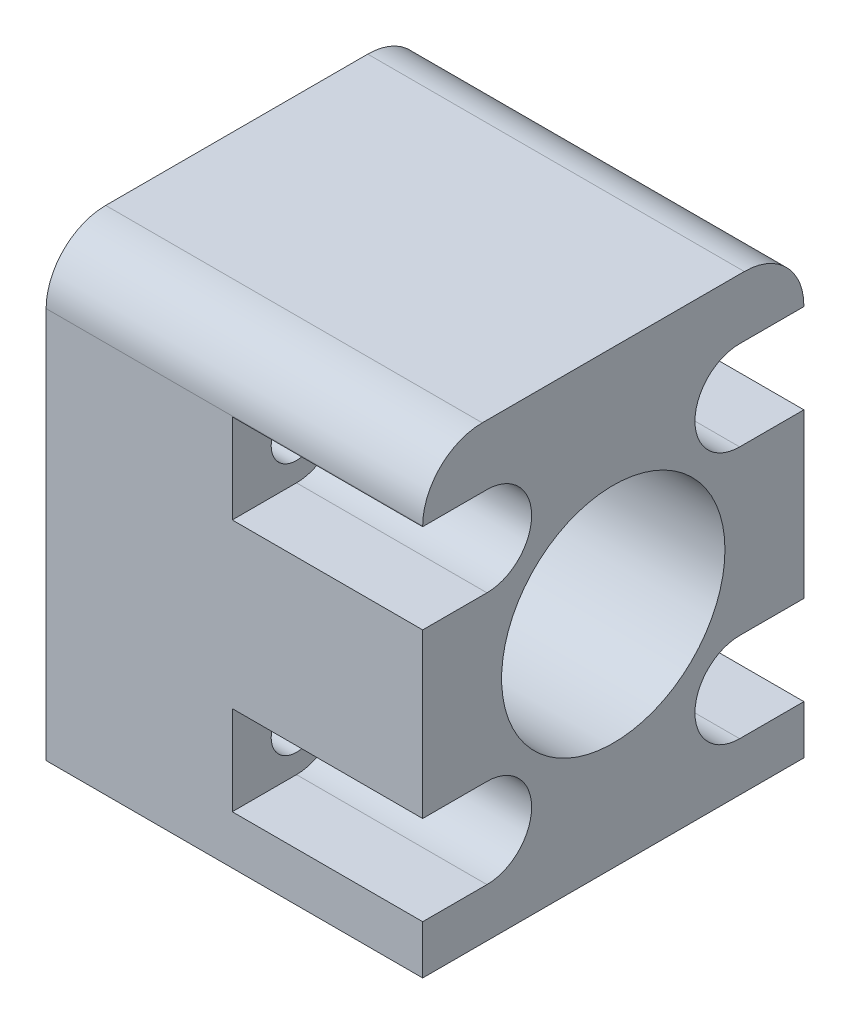
from build123d import *

# Parameters (mm, degrees)
ESQUISSE1_W                  = 59
ESQUISSE1_H                  = 140
ESQUISSE1_R                  = 4
BOSS_EXTRU_1_DEPTH           = 25.6
ESQUISSE2_R                  = 7.5
ESQUISSE2_R_2                = 2.6
ENL_V_MAT_EXTRU_1_DEPTH      = 5
ESQUISSE3_R                  = 7.5
ENL_V_MAT_EXTRU_2_DEPTH      = 82
ESQUISSE4_R                  = 2.6
ENL_V_MAT_EXTRU_3_DEPTH      = 5
CONG_1_R                     = 4
ESQUISSE5_R                  = 1.7
ENL_V_MAT_EXTRU_4_DEPTH      = 71
ENL_V_MAT_EXTRU_5_DEPTH      = 17
ENL_V_MAT_EXTRU_5_DEPTH_BACK = 17
ESQUISSE7_W                  = 129.758897747
ESQUISSE7_H                  = 47.788995409
ENL_V_MAT_EXTRU_6_DEPTH      = 109.711687575
ESQUISSE8_W                  = 39.97313833
ESQUISSE8_H                  = 58.643042411
ENL_V_MAT_EXTRU_7_DEPTH      = 33.711687575


with BuildPart() as part:
    # Esquisse1 → Boss.-Extru.1 (new body)
    with BuildSketch(Plane.XY):
        with Locations((91.26696752, -67.893899255)):
            Rectangle(ESQUISSE1_W, ESQUISSE1_H)
        with Locations((115.36696752, -108.722960996)):
            Circle(ESQUISSE1_R, mode=Mode.SUBTRACT)
        with Locations((115.36696752, -26.122960996)):
            Circle(ESQUISSE1_R, mode=Mode.SUBTRACT)
        with Locations((74.86696752, -56.866619083)):
            Circle(ESQUISSE1_R, mode=Mode.SUBTRACT)
        with Locations((67.16696752, -107.582960996)):
            Circle(ESQUISSE1_R, mode=Mode.SUBTRACT)
        with Locations((67.16696752, -32.342960996)):
            Circle(ESQUISSE1_R, mode=Mode.SUBTRACT)
    extrude(amount=BOSS_EXTRU_1_DEPTH)

    # Esquisse2 → Enlèv. mat.-Extru.1 (cut)
    with BuildSketch(Plane(origin=(120.76696752, 0, 0), x_dir=(0, 0, -1), z_dir=(1, 0, 0))):
        with Locations((-12.8, -95.02835166)):
            Circle(ESQUISSE2_R)
        with Locations((-21.285281374, -103.629375049)):
            Circle(ESQUISSE2_R_2)
        with Locations((-4.314718626, -103.629375049)):
            Circle(ESQUISSE2_R_2)
        with Locations((-4.314718626, -86.427328272)):
            Circle(ESQUISSE2_R_2)
        with Locations((-21.285281374, -86.427328272)):
            Circle(ESQUISSE2_R_2)
        with Locations((-21.285281374, -133.513633034)):
            Circle(ESQUISSE2_R_2)
        with Locations((-12.8, -125.02835166)):
            Circle(ESQUISSE2_R)
        with Locations((-4.314718626, -133.513633034)):
            Circle(ESQUISSE2_R_2)
        with Locations((-4.314718626, -69.225281495)):
            Circle(ESQUISSE2_R_2)
        with Locations((-21.285281374, -69.225281495)):
            Circle(ESQUISSE2_R_2)
        with Locations((-12.8, -77.826304883)):
            Circle(ESQUISSE2_R)
        with Locations((-4.314718626, -52.023234718)):
            Circle(ESQUISSE2_R_2)
        with Locations((-21.285281374, -52.023234718)):
            Circle(ESQUISSE2_R_2)
        with Locations((-12.8, -60.624258106)):
            Circle(ESQUISSE2_R)
        with Locations((-4.314718626, -34.821187941)):
            Circle(ESQUISSE2_R_2)
        with Locations((-21.285281374, -34.821187941)):
            Circle(ESQUISSE2_R_2)
        with Locations((-12.8, -43.422211329)):
            Circle(ESQUISSE2_R)
        with Locations((-12.8, -13.422211329)):
            Circle(ESQUISSE2_R)
        with Locations((-21.285281374, -4.936929955)):
            Circle(ESQUISSE2_R_2)
        with Locations((-4.314718626, -4.936929955)):
            Circle(ESQUISSE2_R_2)
        with Locations((-4.314718626, -116.543070286)):
            Circle(ESQUISSE2_R_2)
        with Locations((-21.285281374, -116.543070286)):
            Circle(ESQUISSE2_R_2)
        with Locations((-4.314718626, -21.907492704)):
            Circle(ESQUISSE2_R_2)
        with Locations((-21.285281374, -21.907492704)):
            Circle(ESQUISSE2_R_2)
    extrude(amount=-ENL_V_MAT_EXTRU_1_DEPTH, mode=Mode.SUBTRACT)

    # Esquisse3 → Enlèv. mat.-Extru.2 (cut)
    with BuildSketch(Plane(origin=(120.76696752, 0, 0), x_dir=(0, 0, -1), z_dir=(1, 0, 0))):
        with Locations((-12.8, -125.02835166)):
            Circle(ESQUISSE3_R)
        with Locations((-12.8, -95.02835166)):
            Circle(ESQUISSE3_R)
        with Locations((-12.8, -77.826304883)):
            Circle(ESQUISSE3_R)
        with Locations((-12.8, -60.624258106)):
            Circle(ESQUISSE3_R)
        with Locations((-12.8, -43.422211329)):
            Circle(ESQUISSE3_R)
        with Locations((-12.8, -13.422211329)):
            Circle(ESQUISSE3_R)
    extrude(amount=-ENL_V_MAT_EXTRU_2_DEPTH, mode=Mode.SUBTRACT)

    # Esquisse4 → Enlèv. mat.-Extru.3 (cut)
    with BuildSketch(Plane.ZY.offset(-61.76696752)):
        with Locations((21.285281374, -4.936929955)):
            Circle(ESQUISSE4_R)
        with Locations((4.314718626, -4.936929955)):
            Circle(ESQUISSE4_R)
        with Locations((21.285281374, -34.936929955)):
            Circle(ESQUISSE4_R)
        with Locations((4.314718626, -34.936929955)):
            Circle(ESQUISSE4_R)
        with Locations((4.314718626, -51.907492704)):
            Circle(ESQUISSE4_R)
        with Locations((21.285281374, -51.907492704)):
            Circle(ESQUISSE4_R)
        with Locations((4.314718626, -69.341023509)):
            Circle(ESQUISSE4_R)
        with Locations((21.285281374, -69.341023509)):
            Circle(ESQUISSE4_R)
        with Locations((4.314718626, -86.311586257)):
            Circle(ESQUISSE4_R)
        with Locations((21.285281374, -86.311586257)):
            Circle(ESQUISSE4_R)
        with Locations((4.314718626, -103.745117063)):
            Circle(ESQUISSE4_R)
        with Locations((21.285281374, -103.745117063)):
            Circle(ESQUISSE4_R)
        with Locations((4.314718626, -133.513633034)):
            Circle(ESQUISSE4_R)
        with Locations((21.285281374, -133.513633034)):
            Circle(ESQUISSE4_R)
        with Locations((4.314718626, -21.907492704)):
            Circle(ESQUISSE4_R)
        with Locations((21.285281374, -21.907492704)):
            Circle(ESQUISSE4_R)
        with Locations((4.314718626, -116.543070286)):
            Circle(ESQUISSE4_R)
        with Locations((21.285281374, -116.543070286)):
            Circle(ESQUISSE4_R)
    extrude(amount=-ENL_V_MAT_EXTRU_3_DEPTH, mode=Mode.SUBTRACT)

    # Congé1
    cong_1_edges = [part.edges().sort_by_distance(p)[0] for p in [
        (91.26696752, 2.106100745, 25.6),
        (91.26696752, 2.106100745, 0),
        (91.26696752, -137.893899255, 0),
        (91.26696752, -137.893899255, 25.6),
    ]]
    fillet(cong_1_edges, radius=CONG_1_R)

    # Esquisse5 → Enlèv. mat.-Extru.4 (cut)
    with BuildSketch(Plane.ZY.offset(-61.76696752)):
        with Locations((21.285281374, -4.936929955)):
            Circle(ESQUISSE5_R)
        with Locations((21.285281374, -21.907492704)):
            Circle(ESQUISSE5_R)
        with Locations((21.285281374, -34.936929955)):
            Circle(ESQUISSE5_R)
        with Locations((21.285281374, -51.907492704)):
            Circle(ESQUISSE5_R)
        with Locations((21.285281374, -69.341023509)):
            Circle(ESQUISSE5_R)
        with Locations((21.285281374, -86.311586257)):
            Circle(ESQUISSE5_R)
        with Locations((21.285281374, -103.745117063)):
            Circle(ESQUISSE5_R)
        with Locations((21.285281374, -116.543070286)):
            Circle(ESQUISSE5_R)
        with Locations((21.285281374, -133.513633034)):
            Circle(ESQUISSE5_R)
        with Locations((4.314718626, -4.936929955)):
            Circle(ESQUISSE5_R)
        with Locations((4.314718626, -21.907492704)):
            Circle(ESQUISSE5_R)
        with Locations((4.314718626, -34.936929955)):
            Circle(ESQUISSE5_R)
        with Locations((4.314718626, -51.907492704)):
            Circle(ESQUISSE5_R)
        with Locations((4.314718626, -69.341023509)):
            Circle(ESQUISSE5_R)
        with Locations((4.314718626, -86.311586257)):
            Circle(ESQUISSE5_R)
        with Locations((4.314718626, -103.745117063)):
            Circle(ESQUISSE5_R)
        with Locations((4.314718626, -116.543070286)):
            Circle(ESQUISSE5_R)
        with Locations((4.314718626, -133.513633034)):
            Circle(ESQUISSE5_R)
    extrude(amount=-ENL_V_MAT_EXTRU_4_DEPTH, mode=Mode.SUBTRACT)

    # Esquisse6 → Enlèv. mat.-Extru.5 (cut, two sides)
    with BuildSketch(Plane.ZY.offset(-91.26696752)) as enl_v_mat_extru_5_sk:
        with BuildLine():
            Line((21.285281374, -1.936929955), (29.285281374, -1.936929955))
            ThreePointArc((29.285281374, -1.936929955), (32.285281374, -4.936929955), (29.285281374, -7.936929955))
            Line((29.285281374, -7.936929955), (21.285281374, -7.936929955))
            ThreePointArc((21.285281374, -7.936929955), (18.285281374, -4.936929955), (21.285281374, -1.936929955))
        make_face()
        with BuildLine():
            Line((21.285281374, -18.907492704), (29.285281374, -18.907492704))
            ThreePointArc((29.285281374, -18.907492704), (32.285281374, -21.907492704), (29.285281374, -24.907492704))
            Line((29.285281374, -24.907492704), (21.285281374, -24.907492704))
            ThreePointArc((21.285281374, -24.907492704), (18.285281374, -21.907492704), (21.285281374, -18.907492704))
        make_face()
        with BuildLine():
            Line((21.285281374, -31.936929955), (29.285281374, -31.936929955))
            ThreePointArc((29.285281374, -31.936929955), (32.285281374, -34.936929955), (29.285281374, -37.936929955))
            Line((29.285281374, -37.936929955), (21.285281374, -37.936929955))
            ThreePointArc((21.285281374, -37.936929955), (18.285281374, -34.936929955), (21.285281374, -31.936929955))
        make_face()
        with BuildLine():
            Line((21.285281374, -48.907492704), (29.285281374, -48.907492704))
            ThreePointArc((29.285281374, -48.907492704), (32.285281374, -51.907492704), (29.285281374, -54.907492704))
            Line((29.285281374, -54.907492704), (21.285281374, -54.907492704))
            ThreePointArc((21.285281374, -54.907492704), (18.285281374, -51.907492704), (21.285281374, -48.907492704))
        make_face()
        with BuildLine():
            Line((21.285281374, -66.341023509), (29.285281374, -66.341023509))
            ThreePointArc((29.285281374, -66.341023509), (32.285281374, -69.341023509), (29.285281374, -72.341023509))
            Line((29.285281374, -72.341023509), (21.285281374, -72.341023509))
            ThreePointArc((21.285281374, -72.341023509), (18.285281374, -69.341023509), (21.285281374, -66.341023509))
        make_face()
        with BuildLine():
            Line((21.285281374, -83.311586257), (29.285281374, -83.311586257))
            ThreePointArc((29.285281374, -83.311586257), (32.285281374, -86.311586257), (29.285281374, -89.311586257))
            Line((29.285281374, -89.311586257), (21.285281374, -89.311586257))
            ThreePointArc((21.285281374, -89.311586257), (18.285281374, -86.311586257), (21.285281374, -83.311586257))
        make_face()
        with BuildLine():
            Line((21.285281374, -100.745117063), (29.285281374, -100.745117063))
            ThreePointArc((29.285281374, -100.745117063), (32.285281374, -103.745117063), (29.285281374, -106.745117063))
            Line((29.285281374, -106.745117063), (21.285281374, -106.745117063))
            ThreePointArc((21.285281374, -106.745117063), (18.285281374, -103.745117063), (21.285281374, -100.745117063))
        make_face()
        with BuildLine():
            Line((21.285281374, -113.543070286), (29.285281374, -113.543070286))
            ThreePointArc((29.285281374, -113.543070286), (32.285281374, -116.543070286), (29.285281374, -119.543070286))
            Line((29.285281374, -119.543070286), (21.285281374, -119.543070286))
            ThreePointArc((21.285281374, -119.543070286), (18.285281374, -116.543070286), (21.285281374, -113.543070286))
        make_face()
        with BuildLine():
            Line((21.285281374, -130.513633034), (29.285281374, -130.513633034))
            ThreePointArc((29.285281374, -130.513633034), (32.285281374, -133.513633034), (29.285281374, -136.513633034))
            Line((29.285281374, -136.513633034), (21.285281374, -136.513633034))
            ThreePointArc((21.285281374, -136.513633034), (18.285281374, -133.513633034), (21.285281374, -130.513633034))
        make_face()
        with BuildLine():
            Line((-3.685281374, -1.936929955), (4.314718626, -1.936929955))
            ThreePointArc((4.314718626, -1.936929955), (7.314718626, -4.936929955), (4.314718626, -7.936929955))
            Line((4.314718626, -7.936929955), (-3.685281374, -7.936929955))
            ThreePointArc((-3.685281374, -7.936929955), (-6.685281374, -4.936929955), (-3.685281374, -1.936929955))
        make_face()
        with BuildLine():
            Line((-3.685281374, -18.907492704), (4.314718626, -18.907492704))
            ThreePointArc((4.314718626, -18.907492704), (7.314718626, -21.907492704), (4.314718626, -24.907492704))
            Line((4.314718626, -24.907492704), (-3.685281374, -24.907492704))
            ThreePointArc((-3.685281374, -24.907492704), (-6.685281374, -21.907492704), (-3.685281374, -18.907492704))
        make_face()
        with BuildLine():
            Line((-3.685281374, -31.936929955), (4.314718626, -31.936929955))
            ThreePointArc((4.314718626, -31.936929955), (7.314718626, -34.936929955), (4.314718626, -37.936929955))
            Line((4.314718626, -37.936929955), (-3.685281374, -37.936929955))
            ThreePointArc((-3.685281374, -37.936929955), (-6.685281374, -34.936929955), (-3.685281374, -31.936929955))
        make_face()
        with BuildLine():
            Line((-3.685281374, -48.907492704), (4.314718626, -48.907492704))
            ThreePointArc((4.314718626, -48.907492704), (7.314718626, -51.907492704), (4.314718626, -54.907492704))
            Line((4.314718626, -54.907492704), (-3.685281374, -54.907492704))
            ThreePointArc((-3.685281374, -54.907492704), (-6.685281374, -51.907492704), (-3.685281374, -48.907492704))
        make_face()
        with BuildLine():
            Line((-3.685281374, -66.341023509), (4.314718626, -66.341023509))
            ThreePointArc((4.314718626, -66.341023509), (7.314718626, -69.341023509), (4.314718626, -72.341023509))
            Line((4.314718626, -72.341023509), (-3.685281374, -72.341023509))
            ThreePointArc((-3.685281374, -72.341023509), (-6.685281374, -69.341023509), (-3.685281374, -66.341023509))
        make_face()
        with BuildLine():
            Line((-3.685281374, -83.311586257), (4.314718626, -83.311586257))
            ThreePointArc((4.314718626, -83.311586257), (7.314718626, -86.311586257), (4.314718626, -89.311586257))
            Line((4.314718626, -89.311586257), (-3.685281374, -89.311586257))
            ThreePointArc((-3.685281374, -89.311586257), (-6.685281374, -86.311586257), (-3.685281374, -83.311586257))
        make_face()
        with BuildLine():
            Line((-3.685281374, -100.745117063), (4.314718626, -100.745117063))
            ThreePointArc((4.314718626, -100.745117063), (7.314718626, -103.745117063), (4.314718626, -106.745117063))
            Line((4.314718626, -106.745117063), (-3.685281374, -106.745117063))
            ThreePointArc((-3.685281374, -106.745117063), (-6.685281374, -103.745117063), (-3.685281374, -100.745117063))
        make_face()
        with BuildLine():
            Line((-3.685281374, -113.543070286), (4.314718626, -113.543070286))
            ThreePointArc((4.314718626, -113.543070286), (7.314718626, -116.543070286), (4.314718626, -119.543070286))
            Line((4.314718626, -119.543070286), (-3.685281374, -119.543070286))
            ThreePointArc((-3.685281374, -119.543070286), (-6.685281374, -116.543070286), (-3.685281374, -113.543070286))
        make_face()
        with BuildLine():
            Line((-3.685281374, -130.513633034), (4.314718626, -130.513633034))
            ThreePointArc((4.314718626, -130.513633034), (7.314718626, -133.513633034), (4.314718626, -136.513633034))
            Line((4.314718626, -136.513633034), (-3.685281374, -136.513633034))
            ThreePointArc((-3.685281374, -136.513633034), (-6.685281374, -133.513633034), (-3.685281374, -130.513633034))
        make_face()
    extrude(amount=ENL_V_MAT_EXTRU_5_DEPTH, mode=Mode.SUBTRACT)
    extrude(enl_v_mat_extru_5_sk.sketch, amount=-ENL_V_MAT_EXTRU_5_DEPTH_BACK, mode=Mode.SUBTRACT)

    # Esquisse7 → Enlèv. mat.-Extru.6 (cut)
    with BuildSketch(Plane.XZ.offset(137.893899255)):
        with Locations((94.762580062, 12.839847571)):
            Rectangle(ESQUISSE7_W, ESQUISSE7_H)
    extrude(amount=-ENL_V_MAT_EXTRU_6_DEPTH, mode=Mode.SUBTRACT)

    # Esquisse8 → Enlèv. mat.-Extru.7 (cut)
    with BuildSketch(Plane(origin=(120.76696752, 0, 0), x_dir=(0, 0, -1), z_dir=(1, 0, 0))):
        with Locations((-12.8, -13.422211329)):
            Rectangle(ESQUISSE8_W, ESQUISSE8_H)
    extrude(amount=-ENL_V_MAT_EXTRU_7_DEPTH, mode=Mode.SUBTRACT)


solid = part.part
